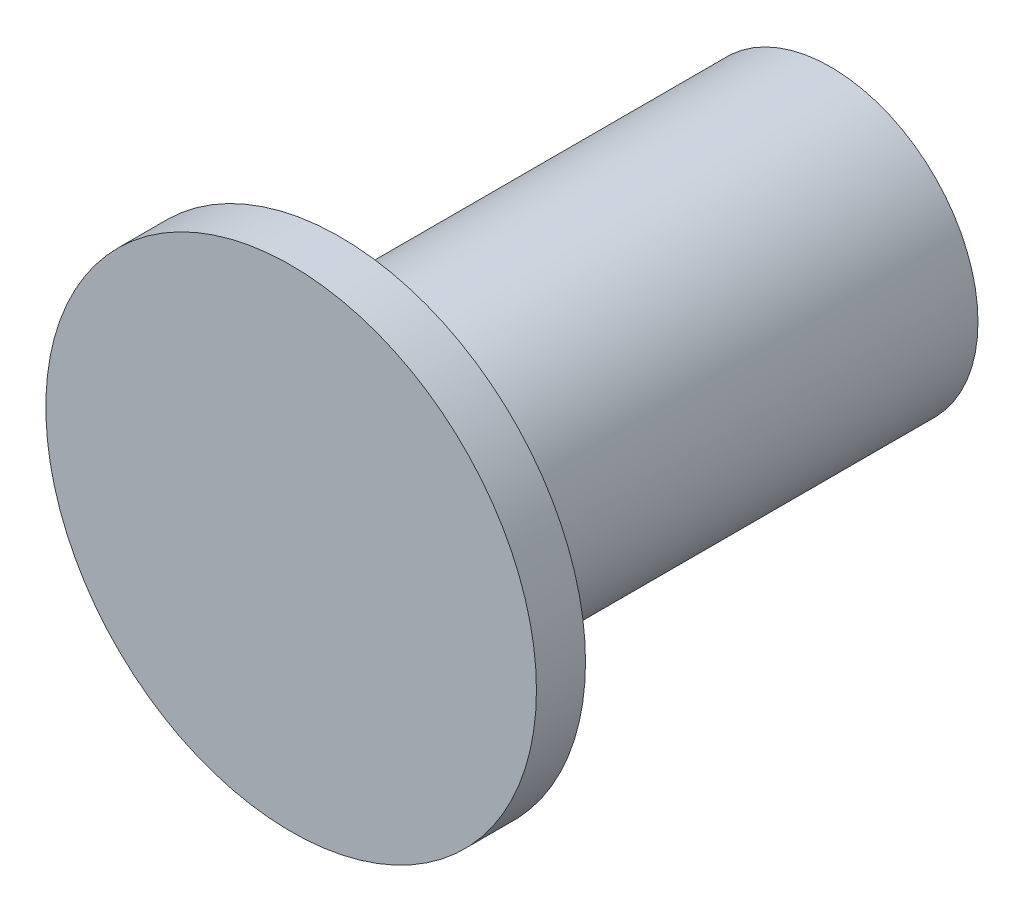
from build123d import *

# Parameters (mm, degrees)
SKETCH_1_R      = 0.3
EXTRUDE_1_DEPTH = 1
SKETCH_2_R      = 0.5
EXTRUDE_2_DEPTH = 0.1


with BuildPart() as part:
    # 草图1 → 凸台-拉伸1 (new body)
    with BuildSketch(Plane.XY):
        Circle(SKETCH_1_R)
    extrude(amount=EXTRUDE_1_DEPTH)

    # 草图2 → 凸台-拉伸2 (add)
    with BuildSketch(Plane.XY.offset(1)):
        Circle(SKETCH_2_R)
    extrude(amount=EXTRUDE_2_DEPTH)


solid = part.part
